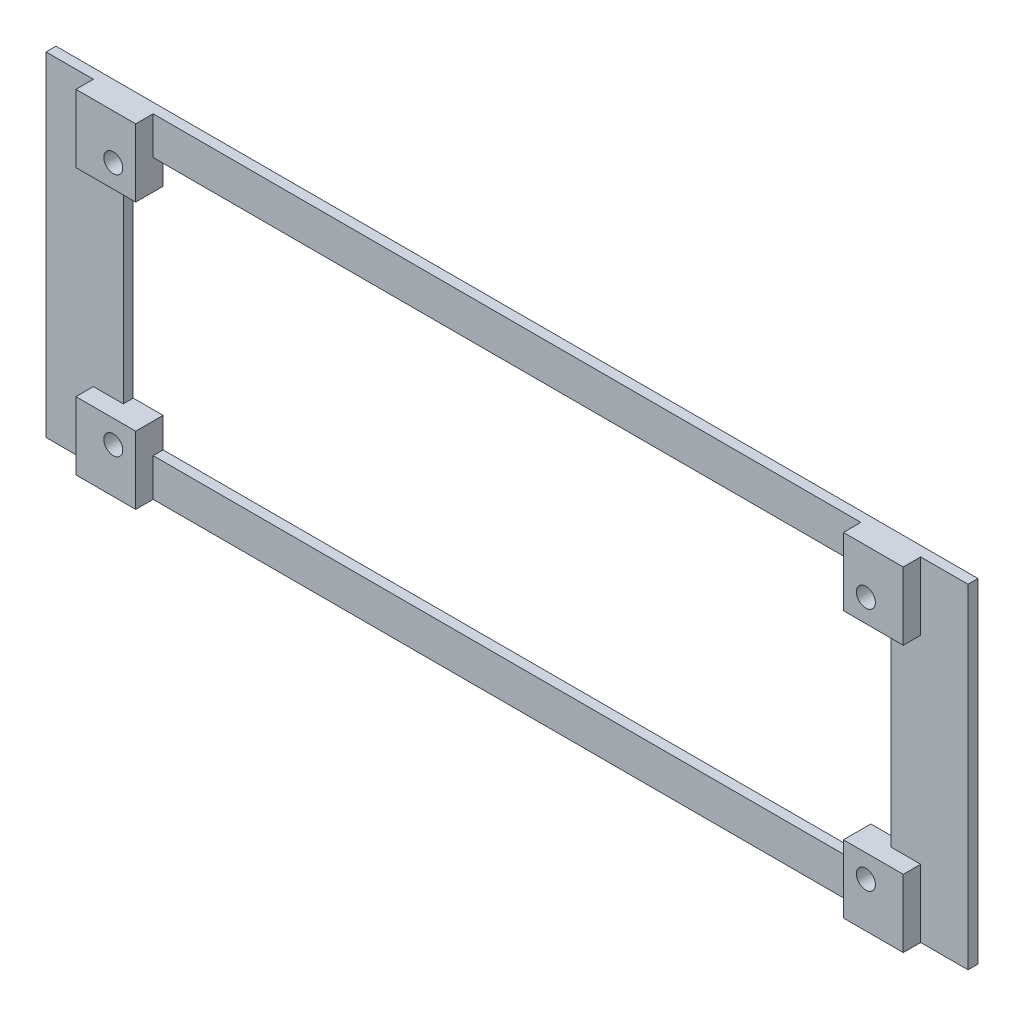
from build123d import *

# Parameters (mm, degrees)
SKICA1_W                                          = 185
SKICA1_H                                          = 67
SKICA1_W_2                                        = 154
SKICA1_H_2                                        = 51.8
SKICA1_W_3                                        = 6
SKICA1_H_3                                        = 6
P_IDAT_VYSUNUT_M1_DEPTH                           = 2
SKICA2_W                                          = 12
SKICA2_H                                          = 13.6
P_IDAT_VYSUNUT_M2_DEPTH                           = 3.5
V_LCOV_ZAHLOUBEN_PRO_M3_ROUBY_S_HLAVO_D           = 3.4
V_LCOV_ZAHLOUBEN_PRO_M3_ROUBY_S_HLAVO_CBORE_D     = 3.8
V_LCOV_ZAHLOUBEN_PRO_M3_ROUBY_S_HLAVO_CBORE_DEPTH = 4


with BuildPart() as part:
    # Skica1 → Přidat vysunutím1 (new body)
    with BuildSketch(Plane.XY):
        Rectangle(SKICA1_W, SKICA1_H)
        Rectangle(SKICA1_W_2, SKICA1_H_2, mode=Mode.SUBTRACT)
        with Locations((-74, 22.9)):
            Rectangle(SKICA1_W_3, SKICA1_H_3)
        with Locations((-74, -22.9)):
            Rectangle(SKICA1_W_3, SKICA1_H_3)
        with Locations((74, -22.9)):
            Rectangle(SKICA1_W_3, SKICA1_H_3)
        with Locations((74, 22.9)):
            Rectangle(SKICA1_W_3, SKICA1_H_3)
    extrude(amount=P_IDAT_VYSUNUT_M1_DEPTH)

    # Skica2 → Přidat vysunutím2 (add)
    with BuildSketch(Plane.XY.offset(2)):
        with Locations((77, 26.7)):
            Rectangle(SKICA2_W, SKICA2_H)
        with Locations((-77, 26.7)):
            Rectangle(SKICA2_W, SKICA2_H)
        with Locations((-77, -26.7)):
            Rectangle(SKICA2_W, SKICA2_H)
        with Locations((77, -26.7)):
            Rectangle(SKICA2_W, SKICA2_H)
    extrude(amount=P_IDAT_VYSUNUT_M2_DEPTH)

    # Válcové zahloubení pro M3 šrouby s hlavou s vnitřním vybráním1 (through all)
    with Locations(Plane.XY.offset(5.5)):
        with Locations((75.5, -24.5), (75.5, 24.5), (-75.5, 24.5), (-75.5, -24.5)):
            CounterBoreHole(V_LCOV_ZAHLOUBEN_PRO_M3_ROUBY_S_HLAVO_D / 2, V_LCOV_ZAHLOUBEN_PRO_M3_ROUBY_S_HLAVO_CBORE_D / 2, V_LCOV_ZAHLOUBEN_PRO_M3_ROUBY_S_HLAVO_CBORE_DEPTH)


solid = part.part
